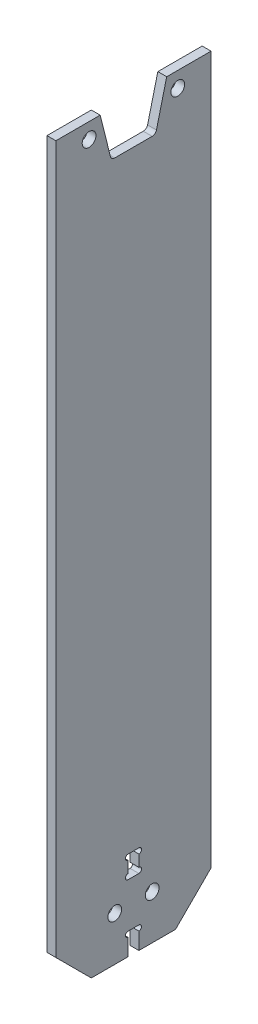
from build123d import *

# Parameters (mm, degrees)
SKETCH_1_W          = 35
SKETCH_1_H          = 167.5
EXTRUDE_1_DEPTH     = 1
SKETCH_2_W          = 2.45
SKETCH_2_H          = 5
CUT_EXTRUDE_1_DEPTH = 3
SKETCH_3_R          = 0.6
CUT_EXTRUDE_2_DEPTH = 3
SKETCH_5_W          = 2.45
SKETCH_5_H          = 5
CUT_EXTRUDE_4_DEPTH = 3
SKETCH_6_R          = 0.6
CUT_EXTRUDE_5_DEPTH = 3
SKETCH_7_R          = 1.55
CUT_EXTRUDE_6_DEPTH = 3
CHAMFER_1_SIZE      = 8
CUT_EXTRUDE_8_DEPTH = 3
FILLET_1_R          = 1
SKETCH_11_R         = 1.55
CUT_EXTRUDE_9_DEPTH = 3


with BuildPart() as part:
    # 草图1 → 凸台-拉伸1 (new body, symmetric)
    with BuildSketch(Plane(origin=(0, 0, 0), x_dir=(0, 0, -1), z_dir=(1, 0, 0))):
        Rectangle(SKETCH_1_W, SKETCH_1_H)
    extrude(amount=EXTRUDE_1_DEPTH, both=True)

    # 草图2 → 切除-拉伸1 (cut, through all)
    with BuildSketch(Plane(origin=(1, 0, 0), x_dir=(0, 0, -1), z_dir=(1, 0, 0))):
        with Locations((0, -81.25)):
            Rectangle(SKETCH_2_W, SKETCH_2_H)
    extrude(amount=-CUT_EXTRUDE_1_DEPTH, mode=Mode.SUBTRACT)

    # 草图3 → 切除-拉伸2 (cut, through all)
    with BuildSketch(Plane(origin=(1, 0, 0), x_dir=(0, 0, -1), z_dir=(1, 0, 0))):
        with Locations((-1.225, -79.35)):
            Circle(SKETCH_3_R)
        with Locations((1.225, -79.35)):
            Circle(SKETCH_3_R)
    extrude(amount=-CUT_EXTRUDE_2_DEPTH, mode=Mode.SUBTRACT)

    # 草图5 → 切除-拉伸4 (cut, through all)
    with BuildSketch(Plane(origin=(1, 0, 0), x_dir=(0, 0, -1), z_dir=(1, 0, 0))):
        with Locations((0, -66.2)):
            Rectangle(SKETCH_5_W, SKETCH_5_H)
    extrude(amount=-CUT_EXTRUDE_4_DEPTH, mode=Mode.SUBTRACT)

    # 草图6 → 切除-拉伸5 (cut, through all)
    with BuildSketch(Plane(origin=(1, 0, 0), x_dir=(0, 0, -1), z_dir=(1, 0, 0))):
        with Locations((-1.225, -64.3)):
            Circle(SKETCH_6_R)
        with Locations((-1.225, -68.1)):
            Circle(SKETCH_6_R)
        with Locations((1.225, -64.3)):
            Circle(SKETCH_6_R)
        with Locations((1.225, -68.1)):
            Circle(SKETCH_6_R)
    extrude(amount=-CUT_EXTRUDE_5_DEPTH, mode=Mode.SUBTRACT)

    # 草图7 → 切除-拉伸6 (cut, through all)
    with BuildSketch(Plane(origin=(1, 0, 0), x_dir=(0, 0, -1), z_dir=(1, 0, 0))):
        with Locations((-4.225, -73.75)):
            Circle(SKETCH_7_R)
        with Locations((4.225, -73.75)):
            Circle(SKETCH_7_R)
    extrude(amount=-CUT_EXTRUDE_6_DEPTH, mode=Mode.SUBTRACT)

    # 倒角1
    chamfer_1_edges = [part.edges().sort_by_distance(p)[0] for p in [
        (0, -83.75, -17.5),
        (0, -83.75, 17.5),
    ]]
    chamfer(chamfer_1_edges, length=CHAMFER_1_SIZE)

    # 草图10 → 切除-拉伸8 (cut, through all)
    with BuildSketch(Plane(origin=(1, 0, 0), x_dir=(0, 0, -1), z_dir=(1, 0, 0))):
        Polygon((7.5, 83.75), (-7.5, 83.75), (-5, 73.75), (5, 73.75), align=None)
    extrude(amount=-CUT_EXTRUDE_8_DEPTH, mode=Mode.SUBTRACT)

    # 圆角1
    fillet_1_edges = [part.edges().sort_by_distance(p)[0] for p in [
        (0, 73.75, 5),
        (0, 73.75, -5),
    ]]
    fillet(fillet_1_edges, radius=FILLET_1_R)

    # 草图11 → 切除-拉伸9 (cut, through all)
    with BuildSketch(Plane(origin=(1, 0, 0), x_dir=(0, 0, -1), z_dir=(1, 0, 0))):
        with Locations((-10, 80.25)):
            Circle(SKETCH_11_R)
        with Locations((10, 80.25)):
            Circle(SKETCH_11_R)
    extrude(amount=-CUT_EXTRUDE_9_DEPTH, mode=Mode.SUBTRACT)


solid = part.part
